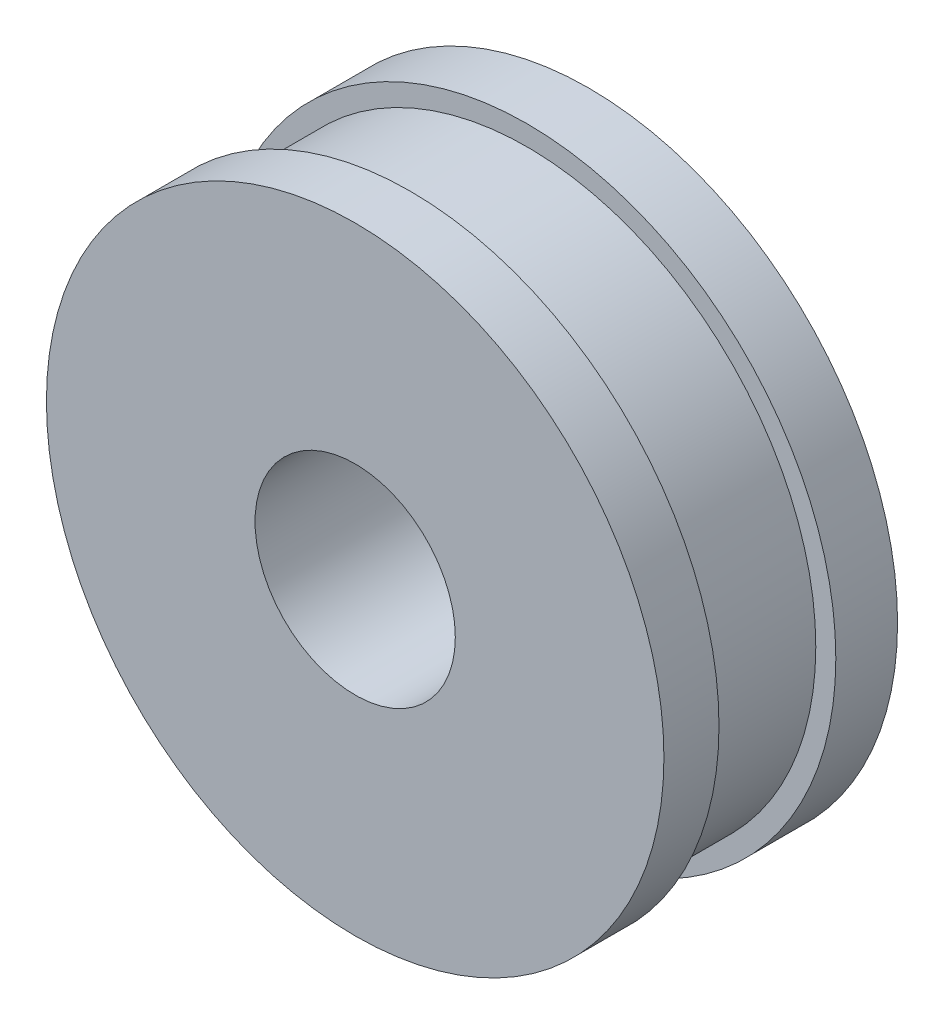
from build123d import *

# Parameters (mm, degrees)
SKETCH_1_R          = 18.5
SKETCH_1_R_2        = 6
EXTRUDE_1_DEPTH     = 14
CUT_EXTRUDE_START   = -2.2
SKETCH_2_R          = 18.5
SKETCH_2_R_2        = 17.3
CUT_EXTRUDE_1_DEPTH = 2.2
SKETCH_2_2_R        = 18.5
SKETCH_2_2_R_2      = 17.3
CUT_EXTRUDE_2_DEPTH = 0.8
CUT_EXTRUDE_START_2 = -4
SKETCH_2_4_R        = 18.5
SKETCH_2_4_R_2      = 17.3
CUT_EXTRUDE_3_DEPTH = 4
SKETCH_2_6_R        = 18.5
SKETCH_2_6_R_2      = 17.3
CUT_EXTRUDE_5_DEPTH = 3


with BuildPart() as part:
    # 草图1 → 凸台-拉伸1 (new body)
    with BuildSketch(Plane.XY):
        Circle(SKETCH_1_R)
        Circle(SKETCH_1_R_2, mode=Mode.SUBTRACT)
    extrude(amount=EXTRUDE_1_DEPTH)

    # 草图2 → 切除-拉伸1 (cut)
    with BuildSketch(Plane.XY.offset(7.7).offset(CUT_EXTRUDE_START)):
        Circle(SKETCH_2_R)
        Circle(SKETCH_2_R_2, mode=Mode.SUBTRACT)
    extrude(amount=CUT_EXTRUDE_1_DEPTH, mode=Mode.SUBTRACT)

    # 草图2<2> → 切除-拉伸2 (cut)
    with BuildSketch(Plane.XY.offset(7.7)):
        Circle(SKETCH_2_2_R)
        Circle(SKETCH_2_2_R_2, mode=Mode.SUBTRACT)
    extrude(amount=CUT_EXTRUDE_2_DEPTH, mode=Mode.SUBTRACT)

    # 草图2<4> → 切除-拉伸3 (cut)
    with BuildSketch(Plane.XY.offset(7.7).offset(CUT_EXTRUDE_START_2)):
        Circle(SKETCH_2_4_R)
        Circle(SKETCH_2_4_R_2, mode=Mode.SUBTRACT)
    extrude(amount=CUT_EXTRUDE_3_DEPTH, mode=Mode.SUBTRACT)

    # 草图2<6> → 切除-拉伸5 (cut)
    with BuildSketch(Plane.XY.offset(7.7)):
        Circle(SKETCH_2_6_R)
        Circle(SKETCH_2_6_R_2, mode=Mode.SUBTRACT)
    extrude(amount=CUT_EXTRUDE_5_DEPTH, mode=Mode.SUBTRACT)


solid = part.part
